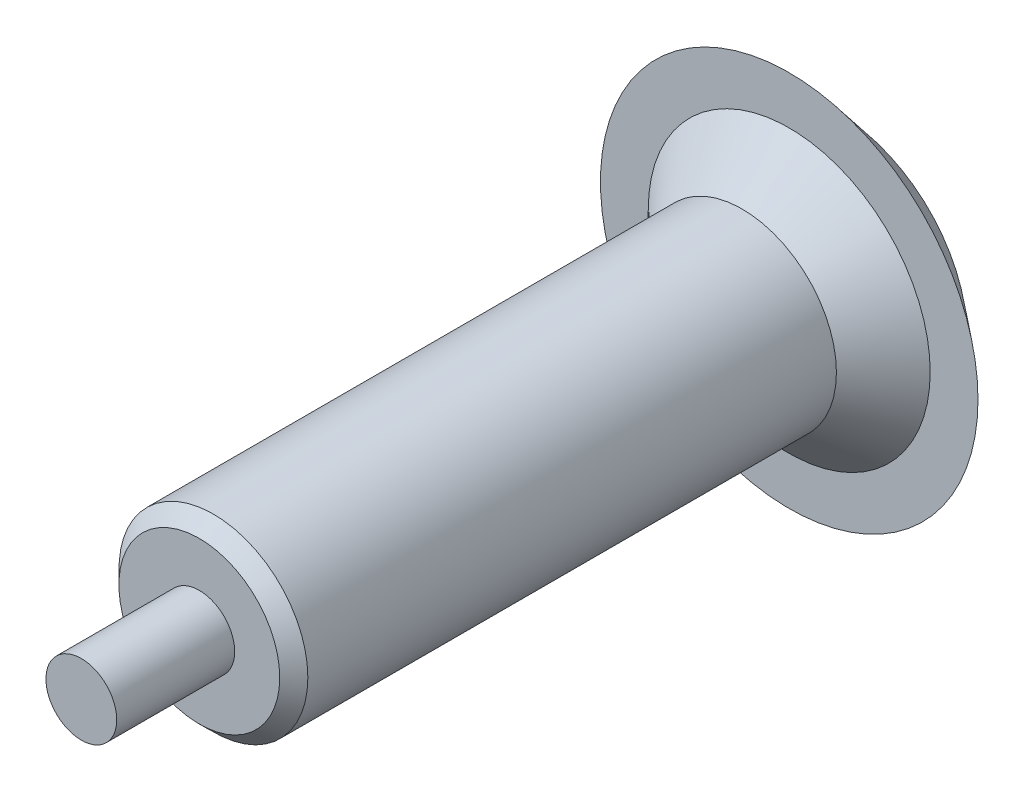
from build123d import *


with BuildPart() as part:
    # Sketch1 → Revolve1 (revolve)
    with BuildSketch(Plane(origin=(0, 0, 0), x_dir=(1, 0, 0), z_dir=(0, 1, 0))):
        Polygon((0, 163.909895321), (27.786536256, 163.909895321), (40, 153.909895321), (29.869465652, 153.909895321), (20, 143.909895321), (20, 31.909895321), (17.039160304, 28.909895321), (7.5, 28.909895321), (7.5, 3.909895321), (0, 3.909895321), align=None)
    revolve(axis=Axis((0, 0, 0), (0, 0, -1)))


solid = part.part
